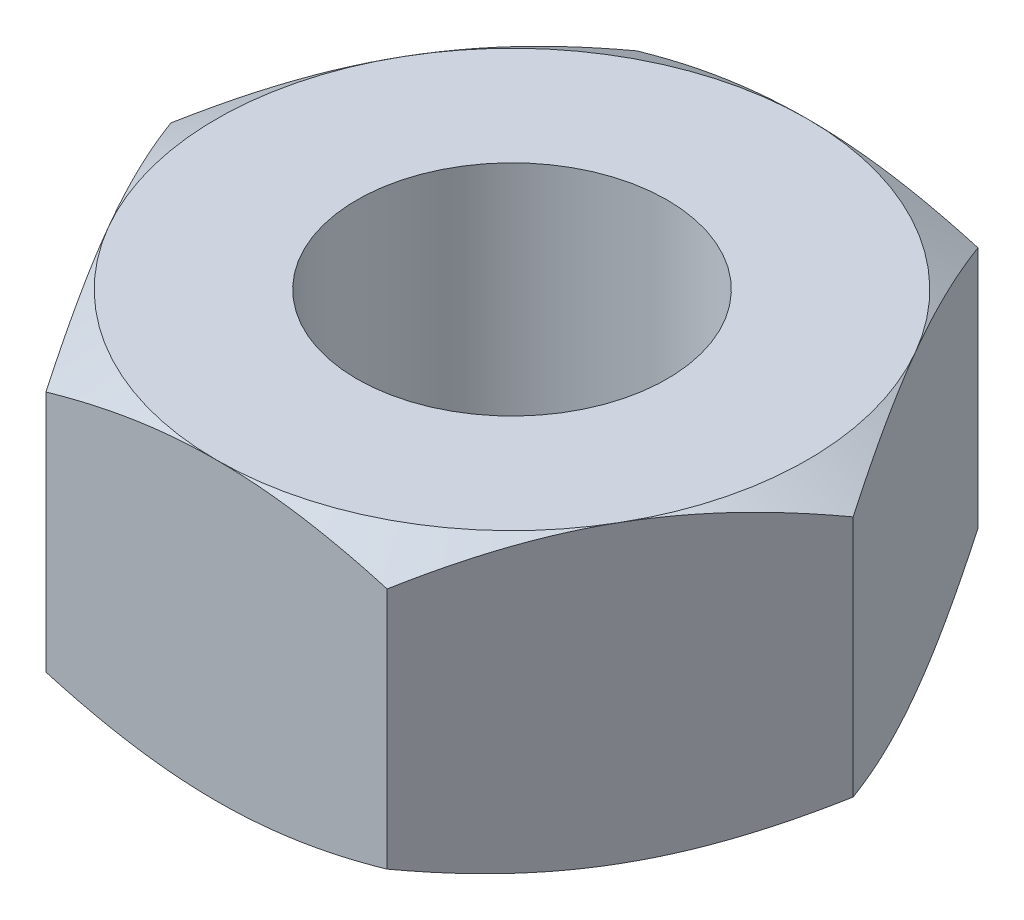
from build123d import *

# Parameters (mm, degrees)
BOSS_EXTRUDE1_DEPTH = 4
M5_TAPPED_HOLE1_D   = 4.2


with BuildPart() as part:
    # Sketch1 → Boss-Extrude1 (new body)
    with BuildSketch(Plane(origin=(0, 0, 0), x_dir=(1, 0, 0), z_dir=(0, 1, 0))):
        Polygon((-2.309401077, -4), (2.309401077, -4), (4.618802154, 0), (2.309401077, 4), (-2.309401077, 4), (-4.618802154, 0), align=None)
    extrude(amount=BOSS_EXTRUDE1_DEPTH)

    # Sketch2 → Cut-Revolve1 (revolve, cut)
    with BuildSketch(Plane(origin=(0, 0, 0), x_dir=(0, 0, -1), z_dir=(1, 0, 0))):
        Polygon((5.752238375, 1.011655298), (4, 0), (5.752238375, 0), align=None)
        Polygon((4, 4), (6.116124346, 4), (6.116124346, 2.778255039), align=None)
    revolve(axis=Axis((0, 0, 0), (0, 1, 0)), mode=Mode.SUBTRACT)

    # M5 Tapped Hole1 (through all)
    with Locations(Plane.ZX.offset(4)):
        with Locations((0, 0)):
            Hole(M5_TAPPED_HOLE1_D / 2)


solid = part.part
